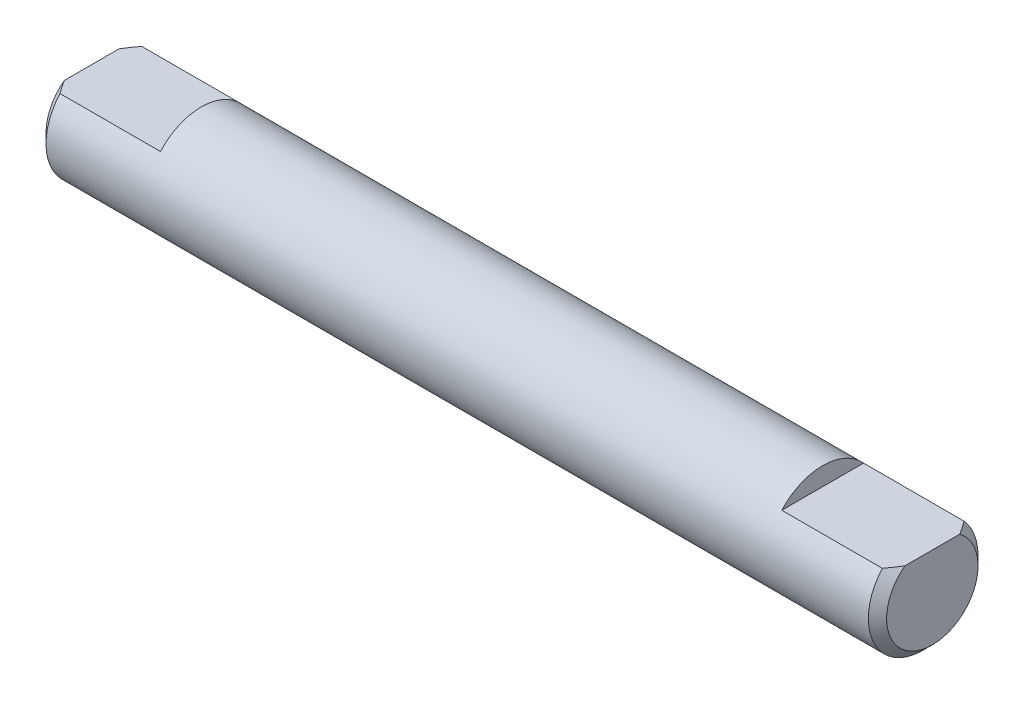
from build123d import *

# Parameters (mm, degrees)
SKETCH1_R           = 3
BOSS_EXTRUDE1_DEPTH = 23
CHAMFER1_SIZE       = 0.5
CUT_EXTRUDE1_DEPTH  = 6


with BuildPart() as part:
    # Sketch1 → Boss-Extrude1 (new body, symmetric)
    with BuildSketch(Plane(origin=(0, 0, 0), x_dir=(0, 0, -1), z_dir=(1, 0, 0))):
        Circle(SKETCH1_R)
    extrude(amount=BOSS_EXTRUDE1_DEPTH, both=True)

    # Chamfer1
    chamfer1_edges = [part.edges().sort_by_distance(p)[0] for p in [
        (-23, 0, 3),
        (23, 0, 3),
    ]]
    chamfer(chamfer1_edges, length=CHAMFER1_SIZE)

    # Sketch2 → Cut-Extrude1 (cut)
    with BuildSketch(Plane(origin=(23, 0, 0), x_dir=(0, 0, -1), z_dir=(1, 0, 0))):
        with BuildLine():
            Line((-2.236067977, 2), (2.236067977, 2))
            ThreePointArc((2.236067977, 2), (0, 3), (-2.236067977, 2))
        make_face()
    cut_extrude1 = extrude(amount=-CUT_EXTRUDE1_DEPTH, mode=Mode.SUBTRACT)

    # Mirror1: Cut-Extrude1 across plane
    add(cut_extrude1.mirror(Plane(origin=(0, 0, 0), x_dir=(0, 0, 1), z_dir=(1, 0, 0))), mode=Mode.SUBTRACT)


solid = part.part
